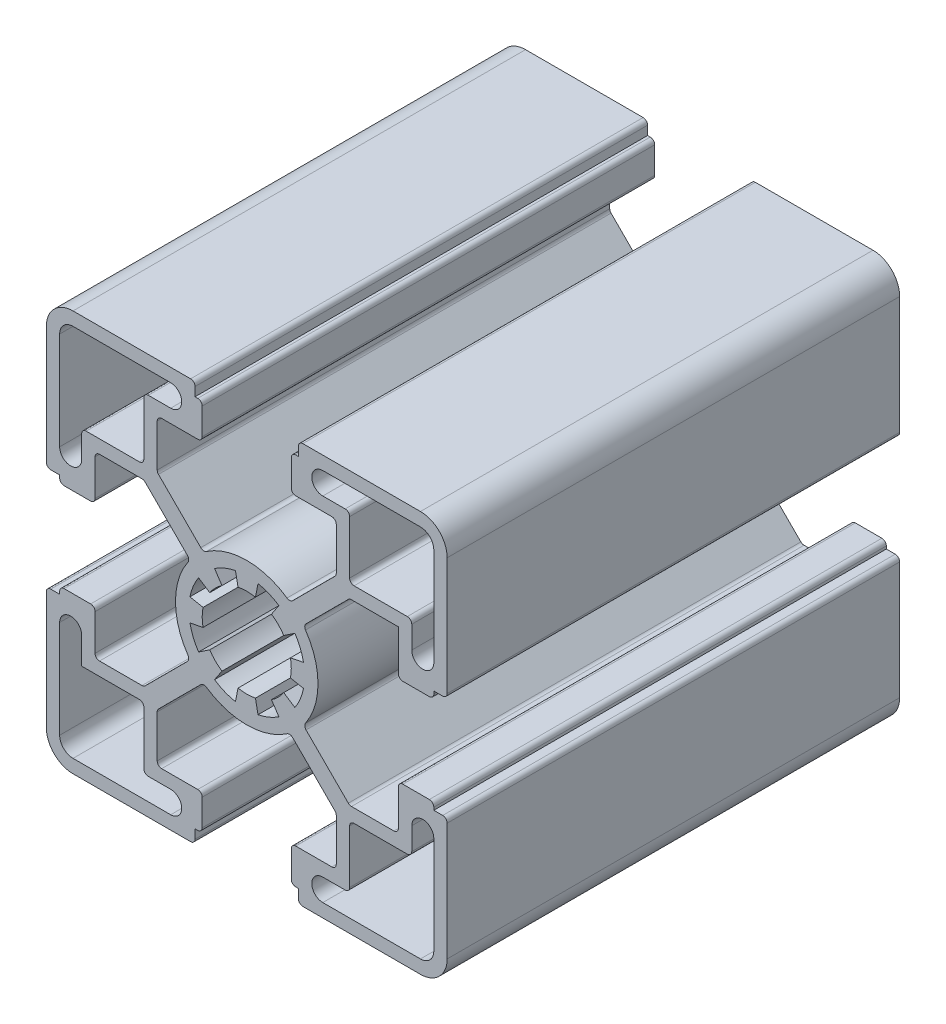
from build123d import *

# Parameters (mm, degrees)
SKETCH3_R           = 5
BOSS_EXTRUDE1_DEPTH = 50.8
FILLET1_R           = 0.5
CUT_EXTRUDE1_DEPTH  = 51.8


with BuildPart() as part:
    # Sketch3 → Boss-Extrude1 (new body)
    with BuildSketch(Plane.XY):
        with BuildLine():
            Line((-11.55, -10.05), (-6.356915373, -4.856915373))
            ThreePointArc((-6.356915373, -4.856915373), (-8, 0), (-6.356915373, 4.856915373))
            Line((-6.356915373, 4.856915373), (-11.55, 10.05))
            Line((-11.55, 10.05), (-17.025, 10.05))
            Line((-17.025, 10.05), (-17.025, 5))
            Line((-17.025, 5), (-21, 5))
            Line((-21, 5), (-21, 5.8))
            Line((-21, 5.8), (-22.5, 5.8))
            Line((-22.5, 5.8), (-22.5, 19.5))
            ThreePointArc((-22.5, 19.5), (-21.621320344, 21.621320344), (-19.5, 22.5))
            Line((-19.5, 22.5), (-5.8, 22.5))
            Line((-5.8, 22.5), (-5.8, 21))
            Line((-5.8, 21), (-5, 21))
            Line((-5, 21), (-5, 17.025))
            Line((-5, 17.025), (-10.05, 17.025))
            Line((-10.05, 17.025), (-10.05, 11.55))
            Line((-10.05, 11.55), (-4.856915373, 6.356915373))
            ThreePointArc((-4.856915373, 6.356915373), (0, 8), (4.856915373, 6.356915373))
            Line((4.856915373, 6.356915373), (10.05, 11.55))
            Line((10.05, 11.55), (10.05, 17.025))
            Line((10.05, 17.025), (5, 17.025))
            Line((5, 17.025), (5, 21))
            Line((5, 21), (5.8, 21))
            Line((5.8, 21), (5.8, 22.5))
            Line((5.8, 22.5), (19.5, 22.5))
            ThreePointArc((19.5, 22.5), (21.621320344, 21.621320344), (22.5, 19.5))
            Line((22.5, 19.5), (22.5, 5.8))
            Line((22.5, 5.8), (21, 5.8))
            Line((21, 5.8), (21, 5))
            Line((21, 5), (17.025, 5))
            Line((17.025, 5), (17.025, 10.05))
            Line((17.025, 10.05), (11.55, 10.05))
            Line((11.55, 10.05), (6.356915373, 4.856915373))
            ThreePointArc((6.356915373, 4.856915373), (8, 0), (6.356915373, -4.856915373))
            Line((6.356915373, -4.856915373), (11.55, -10.05))
            Line((11.55, -10.05), (17.025, -10.05))
            Line((17.025, -10.05), (17.025, -5))
            Line((17.025, -5), (21, -5))
            Line((21, -5), (21, -5.8))
            Line((21, -5.8), (22.5, -5.8))
            Line((22.5, -5.8), (22.5, -19.5))
            ThreePointArc((22.5, -19.5), (21.621320344, -21.621320344), (19.5, -22.5))
            Line((19.5, -22.5), (5.8, -22.5))
            Line((5.8, -22.5), (5.8, -21))
            Line((5.8, -21), (5, -21))
            Line((5, -21), (5, -17.025))
            Line((5, -17.025), (10.05, -17.025))
            Line((10.05, -17.025), (10.05, -11.55))
            Line((10.05, -11.55), (4.856915373, -6.356915373))
            ThreePointArc((4.856915373, -6.356915373), (0, -8), (-4.856915373, -6.356915373))
            Line((-4.856915373, -6.356915373), (-10.05, -11.55))
            Line((-10.05, -11.55), (-10.05, -17.025))
            Line((-10.05, -17.025), (-5, -17.025))
            Line((-5, -17.025), (-5, -21))
            Line((-5, -21), (-5.8, -21))
            Line((-5.8, -21), (-5.8, -22.5))
            Line((-5.8, -22.5), (-19.5, -22.5))
            ThreePointArc((-19.5, -22.5), (-21.621320344, -21.621320344), (-22.5, -19.5))
            Line((-22.5, -19.5), (-22.5, -5.8))
            Line((-22.5, -5.8), (-21, -5.8))
            Line((-21, -5.8), (-21, -5))
            Line((-21, -5), (-17.025, -5))
            Line((-17.025, -5), (-17.025, -10.05))
            Line((-17.025, -10.05), (-11.55, -10.05))
        make_face()
        Circle(SKETCH3_R, mode=Mode.SUBTRACT)
        with BuildLine():
            Line((-21, 8.5375), (-21, 19.5))
            ThreePointArc((-21, 19.5), (-20.560660172, 20.560660172), (-19.5, 21))
            Line((-19.5, 21), (-8.5375, 21))
            ThreePointArc((-8.5375, 21), (-7.3, 19.7625), (-8.5375, 18.525))
            Line((-8.5375, 18.525), (-11.55, 18.525))
            Line((-11.55, 18.525), (-11.55, 11.55))
            Line((-11.55, 11.55), (-18.525, 11.55))
            Line((-18.525, 11.55), (-18.525, 8.5375))
            ThreePointArc((-18.525, 8.5375), (-19.7625, 7.3), (-21, 8.5375))
        make_face(mode=Mode.SUBTRACT)
        with BuildLine():
            Line((8.5375, 21), (19.5, 21))
            ThreePointArc((19.5, 21), (20.560660172, 20.560660172), (21, 19.5))
            Line((21, 19.5), (21, 8.5375))
            ThreePointArc((21, 8.5375), (19.7625, 7.3), (18.525, 8.5375))
            Line((18.525, 8.5375), (18.525, 11.55))
            Line((18.525, 11.55), (11.55, 11.55))
            Line((11.55, 11.55), (11.55, 18.525))
            Line((11.55, 18.525), (8.5375, 18.525))
            ThreePointArc((8.5375, 18.525), (7.3, 19.7625), (8.5375, 21))
        make_face(mode=Mode.SUBTRACT)
        with BuildLine():
            Line((21, -8.5375), (21, -19.5))
            ThreePointArc((21, -19.5), (20.560660172, -20.560660172), (19.5, -21))
            Line((19.5, -21), (8.5375, -21))
            ThreePointArc((8.5375, -21), (7.3, -19.7625), (8.5375, -18.525))
            Line((8.5375, -18.525), (11.55, -18.525))
            Line((11.55, -18.525), (11.55, -11.55))
            Line((11.55, -11.55), (18.525, -11.55))
            Line((18.525, -11.55), (18.525, -8.5375))
            ThreePointArc((18.525, -8.5375), (19.7625, -7.3), (21, -8.5375))
        make_face(mode=Mode.SUBTRACT)
        with BuildLine():
            Line((-8.5375, -21), (-19.5, -21))
            ThreePointArc((-19.5, -21), (-20.560660172, -20.560660172), (-21, -19.5))
            Line((-21, -19.5), (-21, -8.5375))
            ThreePointArc((-21, -8.5375), (-19.7625, -7.3), (-18.525, -8.5375))
            Line((-18.525, -8.5375), (-18.525, -11.55))
            Line((-18.525, -11.55), (-11.55, -11.55))
            Line((-11.55, -11.55), (-11.55, -18.525))
            Line((-11.55, -18.525), (-8.5375, -18.525))
            ThreePointArc((-8.5375, -18.525), (-7.3, -19.7625), (-8.5375, -21))
        make_face(mode=Mode.SUBTRACT)
    extrude(amount=BOSS_EXTRUDE1_DEPTH)

    # Fillet1
    fillet1_edges = [part.edges().sort_by_distance(p)[0] for p in [
        (-11.55, -18.525, 25.4),
        (-11.55, -11.55, 25.4),
        (18.525, -11.55, 25.4),
        (11.55, -11.55, 25.4),
        (11.55, -18.525, 25.4),
        (11.55, 18.525, 25.4),
        (11.55, 11.55, 25.4),
        (18.525, 11.55, 25.4),
        (-18.525, 11.55, 25.4),
        (-11.55, 11.55, 25.4),
        (-11.55, 18.525, 25.4),
        (6.356915373, -4.856915373, 25.4),
        (11.55, -10.05, 25.4),
        (17.025, -10.05, 25.4),
        (17.025, -5, 25.4),
        (21, -5, 25.4),
        (22.5, -5.8, 25.4),
        (5.8, -22.5, 25.4),
        (5, -21, 25.4),
        (5, -17.025, 25.4),
        (10.05, -17.025, 25.4),
        (10.05, -11.55, 25.4),
        (4.856915373, -6.356915373, 25.4),
        (-4.856915373, -6.356915373, 25.4),
        (-10.05, -11.55, 25.4),
        (-10.05, -17.025, 25.4),
        (-5, -17.025, 25.4),
        (-5, -21, 25.4),
        (-5.8, -22.5, 25.4),
        (-22.5, -5.8, 25.4),
        (-21, -5, 25.4),
        (-17.025, -5, 25.4),
        (-17.025, -10.05, 25.4),
        (-11.55, -10.05, 25.4),
        (-6.356915373, -4.856915373, 25.4),
        (-6.356915373, 4.856915373, 25.4),
        (-11.55, 10.05, 25.4),
        (-17.025, 10.05, 25.4),
        (-17.025, 5, 25.4),
        (-21, 5, 25.4),
        (-22.5, 5.8, 25.4),
        (-5.8, 22.5, 25.4),
        (-5, 21, 25.4),
        (-5, 17.025, 25.4),
        (-10.05, 17.025, 25.4),
        (-10.05, 11.55, 25.4),
        (-4.856915373, 6.356915373, 25.4),
        (4.856915373, 6.356915373, 25.4),
        (10.05, 11.55, 25.4),
        (10.05, 17.025, 25.4),
        (5, 17.025, 25.4),
        (5, 21, 25.4),
        (5.8, 22.5, 25.4),
        (22.5, 5.8, 25.4),
        (21, 5, 25.4),
        (17.025, 5, 25.4),
        (11.55, 10.05, 25.4),
        (6.356915373, 4.856915373, 25.4),
    ]]
    fillet(fillet1_edges, radius=FILLET1_R)

    # Sketch4 → Cut-Extrude1 (cut, through all)
    with BuildSketch(Plane.XY.offset(50.8)):
        with BuildLine():
            Line((-1.268087093, 6.375104323), (-0.97545161, 4.903926402))
            ThreePointArc((-0.97545161, 4.903926402), (-1.913417162, 4.619397663), (-2.777851165, 4.157348062))
            Line((-2.777851165, 4.157348062), (-3.611206515, 5.40455248))
            ThreePointArc((-3.611206515, 5.40455248), (-2.48744231, 6.005216961), (-1.268087093, 6.375104323))
        make_face()
        with BuildLine():
            Line((1.268087093, 6.375104323), (0.97545161, 4.903926402))
            ThreePointArc((0.97545161, 4.903926402), (1.913417162, 4.619397663), (2.777851165, 4.157348062))
            Line((2.777851165, 4.157348062), (3.611206515, 5.40455248))
            ThreePointArc((3.611206515, 5.40455248), (2.48744231, 6.005216961), (1.268087093, 6.375104323))
        make_face()
        with BuildLine():
            Line((5.40455248, 3.611206515), (4.157348062, 2.777851165))
            ThreePointArc((4.157348062, 2.777851165), (4.619397663, 1.913417162), (4.903926402, 0.97545161))
            Line((4.903926402, 0.97545161), (6.375104323, 1.268087093))
            ThreePointArc((6.375104323, 1.268087093), (6.005216961, 2.48744231), (5.40455248, 3.611206515))
        make_face()
        with BuildLine():
            Line((6.375104323, -1.268087093), (4.903926402, -0.97545161))
            ThreePointArc((4.903926402, -0.97545161), (4.619397663, -1.913417162), (4.157348062, -2.777851165))
            Line((4.157348062, -2.777851165), (5.40455248, -3.611206515))
            ThreePointArc((5.40455248, -3.611206515), (6.005216961, -2.48744231), (6.375104323, -1.268087093))
        make_face()
        with BuildLine():
            Line((3.611206515, -5.40455248), (2.777851165, -4.157348062))
            ThreePointArc((2.777851165, -4.157348062), (1.913417162, -4.619397663), (0.97545161, -4.903926402))
            Line((0.97545161, -4.903926402), (1.268087093, -6.375104323))
            ThreePointArc((1.268087093, -6.375104323), (2.48744231, -6.005216961), (3.611206515, -5.40455248))
        make_face()
        with BuildLine():
            Line((-1.268087093, -6.375104323), (-0.97545161, -4.903926402))
            ThreePointArc((-0.97545161, -4.903926402), (-1.913417162, -4.619397663), (-2.777851165, -4.157348062))
            Line((-2.777851165, -4.157348062), (-3.611206515, -5.40455248))
            ThreePointArc((-3.611206515, -5.40455248), (-2.48744231, -6.005216961), (-1.268087093, -6.375104323))
        make_face()
        with BuildLine():
            Line((-5.40455248, -3.611206515), (-4.157348062, -2.777851165))
            ThreePointArc((-4.157348062, -2.777851165), (-4.619397663, -1.913417162), (-4.903926402, -0.97545161))
            Line((-4.903926402, -0.97545161), (-6.375104323, -1.268087093))
            ThreePointArc((-6.375104323, -1.268087093), (-6.005216961, -2.48744231), (-5.40455248, -3.611206515))
        make_face()
        with BuildLine():
            Line((-6.375104323, 1.268087093), (-4.903926402, 0.97545161))
            ThreePointArc((-4.903926402, 0.97545161), (-4.619397663, 1.913417162), (-4.157348062, 2.777851165))
            Line((-4.157348062, 2.777851165), (-5.40455248, 3.611206515))
            ThreePointArc((-5.40455248, 3.611206515), (-6.005216961, 2.48744231), (-6.375104323, 1.268087093))
        make_face()
    extrude(amount=-CUT_EXTRUDE1_DEPTH, mode=Mode.SUBTRACT)


solid = part.part
